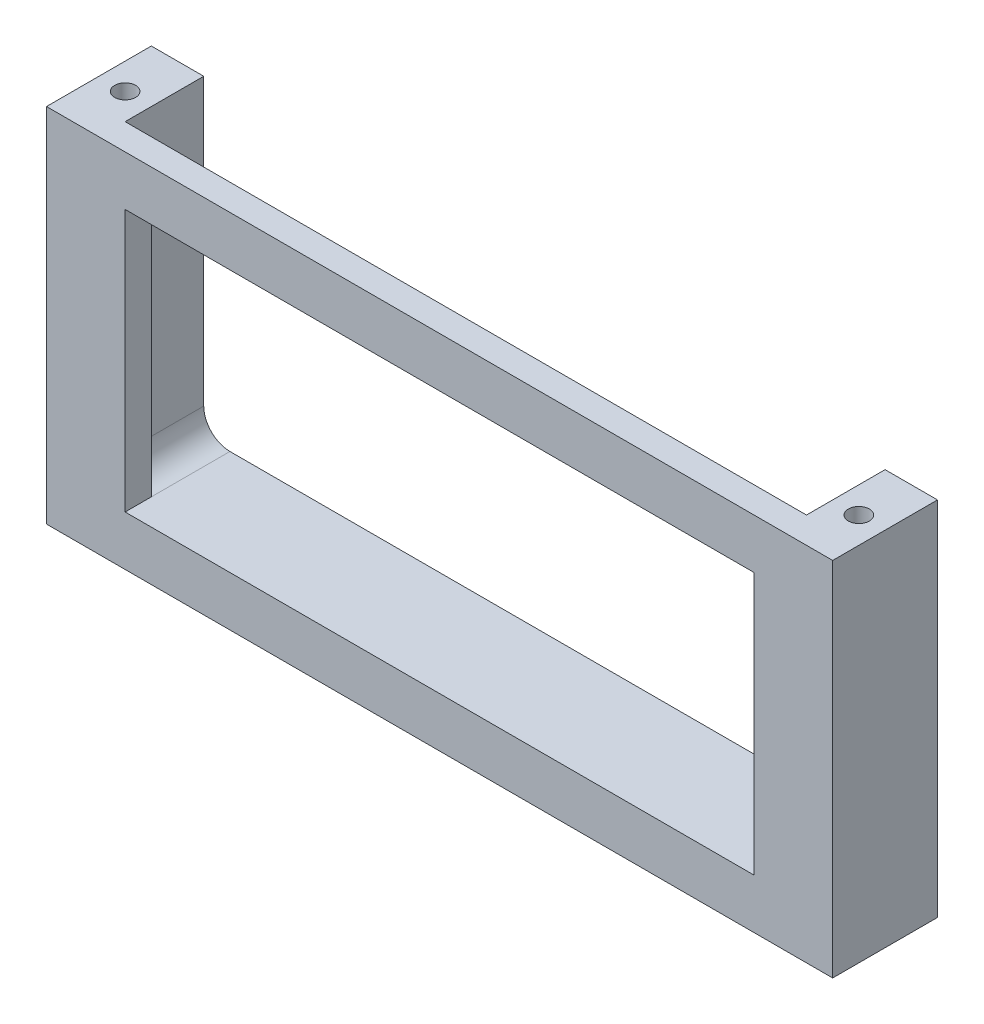
from build123d import *

# Parameters (mm, degrees)
SKETCH1_W                = 130
SKETCH1_H                = 5
BOSS_EXTRUDE1_DEPTH      = 69
SKETCH2_W                = 120
SKETCH2_H                = 50
CUT_EXTRUDE1_DEPTH       = 65
BOSS_EXTRUDE3_DEPTH      = 15
BOSS_EXTRUDE3_DEPTH_BACK = 5
SKETCH4_R                = 2
CUT_EXTRUDE2_DEPTH       = 70
FILLET1_R                = 5


with BuildPart() as part:
    # Sketch1 → Boss-Extrude1 (new body)
    with BuildSketch(Plane(origin=(0, 0, 0), x_dir=(1, 0, 0), z_dir=(0, 1, 0))):
        Rectangle(SKETCH1_W, SKETCH1_H)
    extrude(amount=BOSS_EXTRUDE1_DEPTH)

    # Sketch2 → Cut-Extrude1 (cut)
    with BuildSketch(Plane.XY.offset(2.5)):
        with Locations((0, 34.5)):
            Rectangle(SKETCH2_W, SKETCH2_H)
    extrude(amount=-CUT_EXTRUDE1_DEPTH, mode=Mode.SUBTRACT)

    # Sketch3 → Boss-Extrude3 (add, two sides)
    with BuildSketch(Plane(origin=(0, 0, -2.5), x_dir=(-1, 0, 0), z_dir=(0, 0, -1))) as boss_extrude3_sk:
        Polygon((75, 0), (-75, 0), (-75, 69), (-65, 69), (-65, 9.5), (65, 9.5), (65, 69), (75, 69), align=None)
    extrude(amount=BOSS_EXTRUDE3_DEPTH)
    extrude(boss_extrude3_sk.sketch, amount=-BOSS_EXTRUDE3_DEPTH_BACK)

    # Sketch4 → Cut-Extrude2 (cut, through all)
    with BuildSketch(Plane(origin=(0, 69, 0), x_dir=(1, 0, 0), z_dir=(0, 1, 0))):
        with Locations((-70, 7.5)):
            Circle(SKETCH4_R)
        with Locations((70, 7.5)):
            Circle(SKETCH4_R)
    extrude(amount=-CUT_EXTRUDE2_DEPTH, mode=Mode.SUBTRACT)

    # Fillet1
    fillet1_edges = [part.edges().sort_by_distance(p)[0] for p in [
        (65, 9.5, -10),
        (-65, 9.5, -10),
    ]]
    fillet(fillet1_edges, radius=FILLET1_R)


solid = part.part
